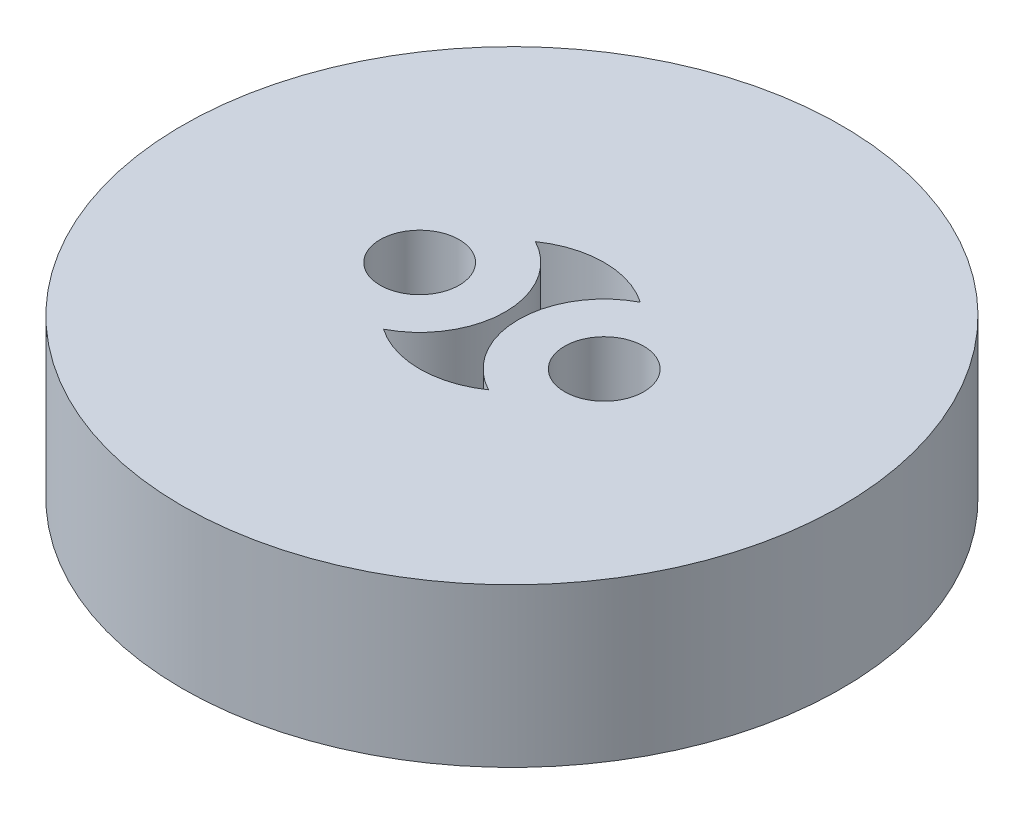
from build123d import *

# Parameters (mm, degrees)
ESQUISSE1_R        = 12.5
ESQUISSE1_R_2      = 1.5
BOSS_EXTRU_1_DEPTH = 6


with BuildPart() as part:
    # Esquisse1 → Boss.-Extru.1 (new body)
    with BuildSketch(Plane(origin=(0, 0, 0), x_dir=(1, 0, 0), z_dir=(0, 1, 0))):
        Circle(ESQUISSE1_R)
        with Locations((-3.5, 0)):
            Circle(ESQUISSE1_R_2, mode=Mode.SUBTRACT)
        with Locations((3.5, 0)):
            Circle(ESQUISSE1_R_2, mode=Mode.SUBTRACT)
        with BuildLine():
            ThreePointArc((1.991071429, 2.878477821), (0.25, 0), (1.991071429, -2.878477821))
            ThreePointArc((1.991071429, -2.878477821), (0, -3.5), (-1.991071429, -2.878477821))
            ThreePointArc((-1.991071429, -2.878477821), (-0.25, 0), (-1.991071429, 2.878477821))
            ThreePointArc((-1.991071429, 2.878477821), (0, 3.5), (1.991071429, 2.878477821))
        make_face(mode=Mode.SUBTRACT)
    extrude(amount=BOSS_EXTRU_1_DEPTH)


solid = part.part
